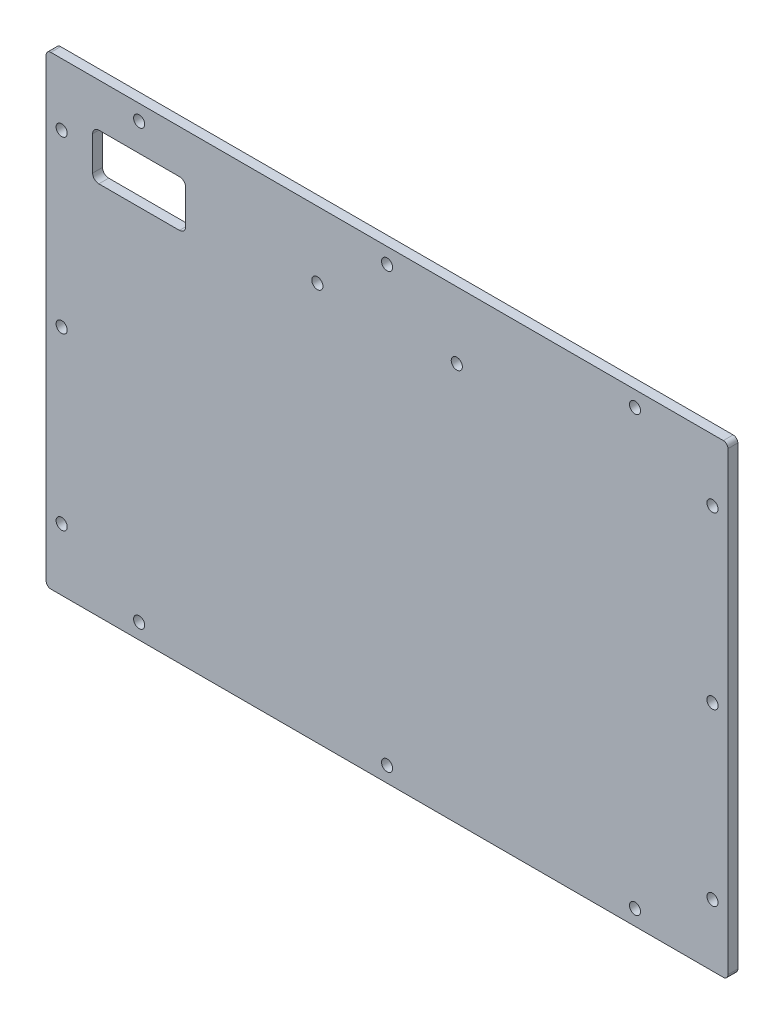
from build123d import *

# Parameters (mm, degrees)
SKETCH1_W            = 220
SKETCH1_H            = 150
BOSS_EXTRUDE1_DEPTH  = 3.175
M3_CLEARANCE_HOLE1_D = 3.6
SKETCH4_W            = 10
SKETCH4_H            = 10
BOSS_EXTRUDE2_DEPTH  = 3.175
FILLET2_R            = 1.5
SKETCH7_W            = 30
SKETCH7_H            = 15
CUT_EXTRUDE2_DEPTH   = 4.175
M3_CLEARANCE_HOLE3_D = 3.6
FILLET3_R            = 2


with BuildPart() as part:
    # Sketch1 → Boss-Extrude1 (new body)
    with BuildSketch(Plane.XY):
        Rectangle(SKETCH1_W, SKETCH1_H)
    extrude(amount=BOSS_EXTRUDE1_DEPTH)

    # M3 Clearance Hole1 (through all)
    with Locations(Plane.XY.offset(3.175)):
        with Locations((0, 0), (-80, 70), (80, 70), (0, 70), (-105, 55), (-105, 0), (-105, -55), (-80, -70), (0, -70), (80, -70), (105, -55), (105, 0), (105, 55)):
            Hole(M3_CLEARANCE_HOLE1_D / 2)

    # Sketch4 → Boss-Extrude2 (add, through all)
    with BuildSketch(Plane.XY.offset(3.175)):
        Rectangle(SKETCH4_W, SKETCH4_H)
    extrude(amount=-BOSS_EXTRUDE2_DEPTH)

    # Fillet2
    fillet2_edges = [part.edges().sort_by_distance(p)[0] for p in [
        (-110, -75, 1.5875),
        (-110, 75, 1.5875),
        (110, 75, 1.5875),
        (110, -75, 1.5875),
    ]]
    fillet(fillet2_edges, radius=FILLET2_R)

    # Sketch7 → Cut-Extrude2 (cut, through all)
    with BuildSketch(Plane.XY.offset(3.175)):
        with Locations((-80, 53.5)):
            Rectangle(SKETCH7_W, SKETCH7_H)
    extrude(amount=-CUT_EXTRUDE2_DEPTH, mode=Mode.SUBTRACT)

    # M3 Clearance Hole3 (through all)
    with Locations(Plane.XY.offset(3.175)):
        with Locations((-22.5, 53.5), (22.5, 53.5)):
            Hole(M3_CLEARANCE_HOLE3_D / 2)

    # Fillet3
    fillet3_edges = [part.edges().sort_by_distance(p)[0] for p in [
        (-65, 61, 1.5875),
        (-65, 46, 1.5875),
        (-95, 46, 1.5875),
        (-95, 61, 1.5875),
    ]]
    fillet(fillet3_edges, radius=FILLET3_R)


solid = part.part
